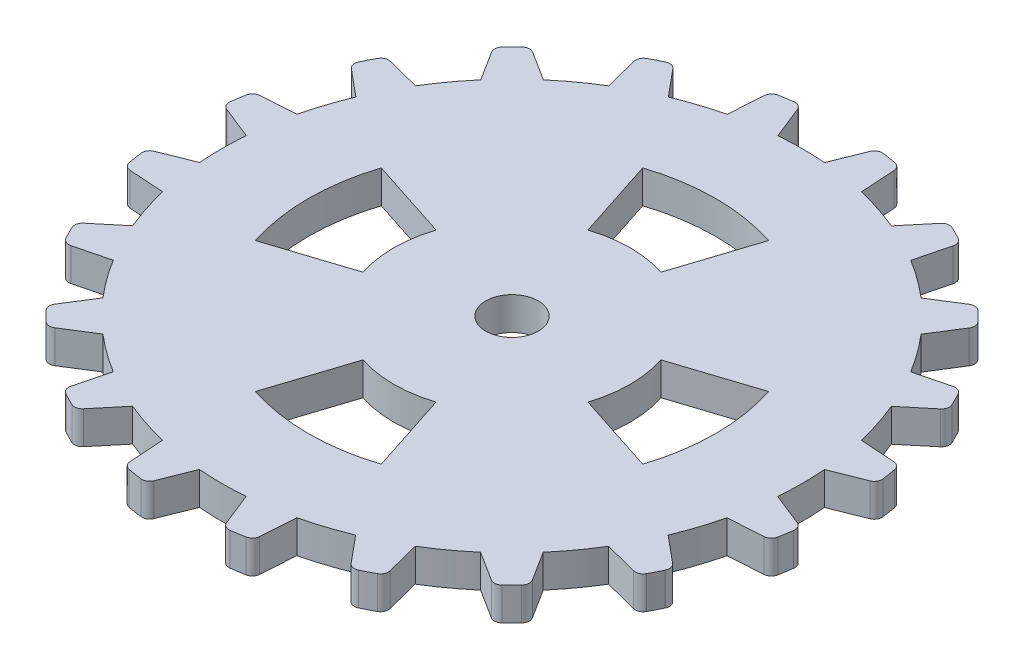
from build123d import *

# Parameters (mm, degrees)
BOSS_EXTRUDE1_DEPTH = 2.5
FILLET1_R           = 0.6
CUT_EXTRUDE1_DEPTH  = 3.5
SKETCH3_R           = 2
CUT_EXTRUDE2_DEPTH  = 3.5


with BuildPart() as part:
    # Sketch1 → Boss-Extrude1 (new body)
    with BuildSketch(Plane(origin=(0, 0, 0), x_dir=(1, 0, 0), z_dir=(0, 1, 0))):
        with BuildLine():
            Line((-1.772401058, 22.011557199), (-2.926428765, 24.911500768))
            ThreePointArc((-2.926428765, 24.911500768), (-3.91732845, 24.775015513), (-4.901998544, 24.59913141))
            Line((-4.901998544, 24.59913141), (-5.105043055, 21.484612895))
            ThreePointArc((-5.105043055, 21.484612895), (-6.818461941, 21.003776627), (-8.487598823, 20.38653286))
            Line((-8.487598823, 20.38653286), (-10.481276239, 22.787928915))
            ThreePointArc((-10.481276239, 22.787928915), (-11.381501578, 22.351918881), (-12.263627311, 21.880363366))
            Line((-12.263627311, 21.880363366), (-11.494294966, 18.855536033))
            ThreePointArc((-11.494294966, 18.855536033), (-12.975266584, 17.868758013), (-14.371971278, 16.765932644))
            Line((-14.371971278, 16.765932644), (-17.010143367, 18.433715807))
            ThreePointArc((-17.010143367, 18.433715807), (-17.731574032, 17.740860694), (-18.424806791, 17.019792906))
            Line((-18.424806791, 17.019792906), (-16.7584052, 14.380747929))
            ThreePointArc((-16.7584052, 14.380747929), (-17.86196173, 12.984620865), (-18.84951505, 11.504166125))
            Line((-18.84951505, 11.504166125), (-21.873939147, 12.275082161))
            ThreePointArc((-21.873939147, 12.275082161), (-22.345956477, 11.393203455), (-22.782437808, 10.493206533))
            Line((-22.782437808, 10.493206533), (-20.38208597, 8.498272022))
            ThreePointArc((-20.38208597, 8.498272022), (-21.00020361, 6.829458558), (-21.481936956, 5.116291672))
            Line((-21.481936956, 5.116291672), (-24.596561357, 4.914877947))
            ThreePointArc((-24.596561357, 4.914877947), (-24.772961008, 3.93030008), (-24.909965079, 2.939471994))
            Line((-24.909965079, 2.939471994), (-22.010626155, 1.783926039))
            ThreePointArc((-22.010626155, 1.783926039), (-22.082799243, 0.005781263), (-22.011557199, -1.772401058))
            Line((-22.011557199, -1.772401058), (-24.911500768, -2.926428765))
            ThreePointArc((-24.911500768, -2.926428765), (-24.775015513, -3.91732845), (-24.59913141, -4.901998544))
            Line((-24.59913141, -4.901998544), (-21.484612895, -5.105043055))
            ThreePointArc((-21.484612895, -5.105043055), (-21.003776627, -6.818461941), (-20.38653286, -8.487598823))
            Line((-20.38653286, -8.487598823), (-22.787928915, -10.481276239))
            ThreePointArc((-22.787928915, -10.481276239), (-22.351918881, -11.381501578), (-21.880363366, -12.263627311))
            Line((-21.880363366, -12.263627311), (-18.855536033, -11.494294966))
            ThreePointArc((-18.855536033, -11.494294966), (-17.868758013, -12.975266584), (-16.765932644, -14.371971278))
            Line((-16.765932644, -14.371971278), (-18.433715807, -17.010143367))
            ThreePointArc((-18.433715807, -17.010143367), (-17.740860694, -17.731574032), (-17.019792906, -18.424806791))
            Line((-17.019792906, -18.424806791), (-14.380747929, -16.7584052))
            ThreePointArc((-14.380747929, -16.7584052), (-12.984620865, -17.86196173), (-11.504166125, -18.84951505))
            Line((-11.504166125, -18.84951505), (-12.275082161, -21.873939147))
            ThreePointArc((-12.275082161, -21.873939147), (-11.393203455, -22.345956477), (-10.493206533, -22.782437808))
            Line((-10.493206533, -22.782437808), (-8.498272022, -20.38208597))
            ThreePointArc((-8.498272022, -20.38208597), (-6.829458558, -21.00020361), (-5.116291672, -21.481936956))
            Line((-5.116291672, -21.481936956), (-4.914877947, -24.596561357))
            ThreePointArc((-4.914877947, -24.596561357), (-3.93030008, -24.772961008), (-2.939471994, -24.909965079))
            Line((-2.939471994, -24.909965079), (-1.783926039, -22.010626155))
            ThreePointArc((-1.783926039, -22.010626155), (-0.005781263, -22.082799243), (1.772401058, -22.011557199))
            Line((1.772401058, -22.011557199), (2.926428765, -24.911500768))
            ThreePointArc((2.926428765, -24.911500768), (3.91732845, -24.775015513), (4.901998544, -24.59913141))
            Line((4.901998544, -24.59913141), (5.105043055, -21.484612895))
            ThreePointArc((5.105043055, -21.484612895), (6.818461941, -21.003776627), (8.487598823, -20.38653286))
            Line((8.487598823, -20.38653286), (10.481276239, -22.787928915))
            ThreePointArc((10.481276239, -22.787928915), (11.381501578, -22.351918881), (12.263627311, -21.880363366))
            Line((12.263627311, -21.880363366), (11.494294966, -18.855536033))
            ThreePointArc((11.494294966, -18.855536033), (12.975266584, -17.868758013), (14.371971278, -16.765932644))
            Line((14.371971278, -16.765932644), (17.010143367, -18.433715807))
            ThreePointArc((17.010143367, -18.433715807), (17.731574032, -17.740860694), (18.424806791, -17.019792906))
            Line((18.424806791, -17.019792906), (16.7584052, -14.380747929))
            ThreePointArc((16.7584052, -14.380747929), (17.86196173, -12.984620865), (18.84951505, -11.504166125))
            Line((18.84951505, -11.504166125), (21.873939147, -12.275082161))
            ThreePointArc((21.873939147, -12.275082161), (22.345956477, -11.393203455), (22.782437808, -10.493206533))
            Line((22.782437808, -10.493206533), (20.38208597, -8.498272022))
            ThreePointArc((20.38208597, -8.498272022), (21.00020361, -6.829458558), (21.481936956, -5.116291672))
            Line((21.481936956, -5.116291672), (24.596561357, -4.914877947))
            ThreePointArc((24.596561357, -4.914877947), (24.772961008, -3.93030008), (24.909965079, -2.939471994))
            Line((24.909965079, -2.939471994), (22.010626155, -1.783926039))
            ThreePointArc((22.010626155, -1.783926039), (22.082799243, -0.005781263), (22.011557199, 1.772401058))
            Line((22.011557199, 1.772401058), (24.911500768, 2.926428765))
            ThreePointArc((24.911500768, 2.926428765), (24.775015513, 3.91732845), (24.59913141, 4.901998544))
            Line((24.59913141, 4.901998544), (21.484612895, 5.105043055))
            ThreePointArc((21.484612895, 5.105043055), (21.003776627, 6.818461941), (20.38653286, 8.487598823))
            Line((20.38653286, 8.487598823), (22.787928915, 10.481276239))
            ThreePointArc((22.787928915, 10.481276239), (22.351918881, 11.381501578), (21.880363366, 12.263627311))
            Line((21.880363366, 12.263627311), (18.855536033, 11.494294966))
            ThreePointArc((18.855536033, 11.494294966), (17.868758013, 12.975266584), (16.765932644, 14.371971278))
            Line((16.765932644, 14.371971278), (18.433715807, 17.010143367))
            ThreePointArc((18.433715807, 17.010143367), (17.740860694, 17.731574032), (17.019792906, 18.424806791))
            Line((17.019792906, 18.424806791), (14.380747929, 16.7584052))
            ThreePointArc((14.380747929, 16.7584052), (12.984620865, 17.86196173), (11.504166125, 18.84951505))
            Line((11.504166125, 18.84951505), (12.275082161, 21.873939147))
            ThreePointArc((12.275082161, 21.873939147), (11.393203455, 22.345956477), (10.493206533, 22.782437808))
            Line((10.493206533, 22.782437808), (8.498272022, 20.38208597))
            ThreePointArc((8.498272022, 20.38208597), (6.829458558, 21.00020361), (5.116291672, 21.481936956))
            Line((5.116291672, 21.481936956), (4.914877947, 24.596561357))
            ThreePointArc((4.914877947, 24.596561357), (3.93030008, 24.772961008), (2.939471994, 24.909965079))
            Line((2.939471994, 24.909965079), (1.783926039, 22.010626155))
            ThreePointArc((1.783926039, 22.010626155), (0.005781263, 22.082799243), (-1.772401058, 22.011557199))
        make_face()
    extrude(amount=-BOSS_EXTRUDE1_DEPTH)

    # Fillet1
    fillet1_edges = [part.edges().sort_by_distance(p)[0] for p in [
        (2.939471994, -1.25, -24.909965079),
        (4.914877947, -1.25, -24.596561357),
        (10.493206533, -1.25, -22.782437808),
        (12.275082161, -1.25, -21.873939147),
        (17.019792906, -1.25, -18.424806791),
        (18.433715807, -1.25, -17.010143367),
        (21.880363366, -1.25, -12.263627311),
        (22.787928915, -1.25, -10.481276239),
        (24.59913141, -1.25, -4.901998544),
        (24.911500768, -1.25, -2.926428765),
        (24.909965079, -1.25, 2.939471994),
        (24.596561357, -1.25, 4.914877947),
        (22.782437808, -1.25, 10.493206533),
        (21.873939147, -1.25, 12.275082161),
        (18.424806791, -1.25, 17.019792906),
        (17.010143367, -1.25, 18.433715807),
        (12.263627311, -1.25, 21.880363366),
        (10.481276239, -1.25, 22.787928915),
        (4.901998544, -1.25, 24.59913141),
        (2.926428765, -1.25, 24.911500768),
        (-2.939471994, -1.25, 24.909965079),
        (-4.914877947, -1.25, 24.596561357),
        (-10.493206533, -1.25, 22.782437808),
        (-12.275082161, -1.25, 21.873939147),
        (-17.019792906, -1.25, 18.424806791),
        (-18.433715807, -1.25, 17.010143367),
        (-21.880363366, -1.25, 12.263627311),
        (-22.787928915, -1.25, 10.481276239),
        (-24.59913141, -1.25, 4.901998544),
        (-24.911500768, -1.25, 2.926428765),
        (-24.909965079, -1.25, -2.939471994),
        (-24.596561357, -1.25, -4.914877947),
        (-22.782437808, -1.25, -10.493206533),
        (-21.873939147, -1.25, -12.275082161),
        (-18.424806791, -1.25, -17.019792906),
        (-17.010143367, -1.25, -18.433715807),
        (-12.263627311, -1.25, -21.880363366),
        (-10.481276239, -1.25, -22.787928915),
        (-4.901998544, -1.25, -24.59913141),
        (-2.926428765, -1.25, -24.911500768),
    ]]
    fillet(fillet1_edges, radius=FILLET1_R)

    # Sketch2 → Cut-Extrude1 (cut, through all)
    with BuildSketch(Plane.XZ.offset(2.5)):
        with BuildLine():
            ThreePointArc((-4.789763413, -14.741376003), (0, -15.5), (4.789763413, -14.741376003))
            Line((4.789763413, -14.741376003), (2.781152949, -8.559508647))
            ThreePointArc((2.781152949, -8.559508647), (0, -9), (-2.781152949, -8.559508647))
            Line((-2.781152949, -8.559508647), (-4.789763413, -14.741376003))
        make_face()
        with BuildLine():
            Line((8.559508647, -2.781152949), (14.741376003, -4.789763413))
            ThreePointArc((14.741376003, -4.789763413), (15.309169279, -2.424734208), (15.5, 0))
            ThreePointArc((15.5, 0), (15.309169279, 2.424734208), (14.741376003, 4.789763413))
            Line((14.741376003, 4.789763413), (8.559508647, 2.781152949))
            ThreePointArc((8.559508647, 2.781152949), (8.889195065, 1.407910185), (9, 0))
            ThreePointArc((9, 0), (8.889195065, -1.407910185), (8.559508647, -2.781152949))
        make_face()
        with BuildLine():
            Line((2.781152949, 8.559508647), (4.789763413, 14.741376003))
            ThreePointArc((4.789763413, 14.741376003), (0, 15.5), (-4.789763413, 14.741376003))
            Line((-4.789763413, 14.741376003), (-2.781152949, 8.559508647))
            ThreePointArc((-2.781152949, 8.559508647), (0, 9), (2.781152949, 8.559508647))
        make_face()
        with BuildLine():
            ThreePointArc((-14.741376003, 4.789763413), (-15.5, 0), (-14.741376003, -4.789763413))
            Line((-14.741376003, -4.789763413), (-8.559508647, -2.781152949))
            ThreePointArc((-8.559508647, -2.781152949), (-9, 0), (-8.559508647, 2.781152949))
            Line((-8.559508647, 2.781152949), (-14.741376003, 4.789763413))
        make_face()
    extrude(amount=-CUT_EXTRUDE1_DEPTH, mode=Mode.SUBTRACT)

    # Sketch3 → Cut-Extrude2 (cut, through all)
    with BuildSketch(Plane.XZ.offset(2.5)):
        Circle(SKETCH3_R)
    extrude(amount=-CUT_EXTRUDE2_DEPTH, mode=Mode.SUBTRACT)


solid = part.part
